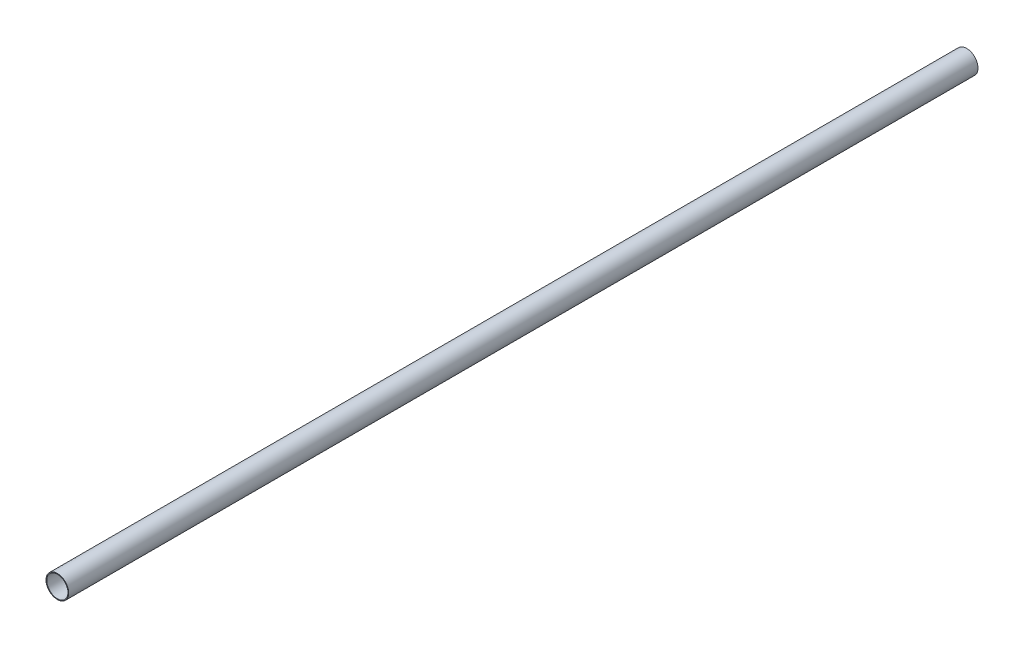
from build123d import *

# Parameters (mm, degrees)
SKETCH1_R           = 15
SKETCH1_R_2         = 14
BOSS_EXTRUDE1_DEPTH = 1200


with BuildPart() as part:
    # Sketch1 → Boss-Extrude1 (new body)
    with BuildSketch(Plane.XY):
        Circle(SKETCH1_R)
        Circle(SKETCH1_R_2, mode=Mode.SUBTRACT)
    extrude(amount=BOSS_EXTRUDE1_DEPTH)


solid = part.part
